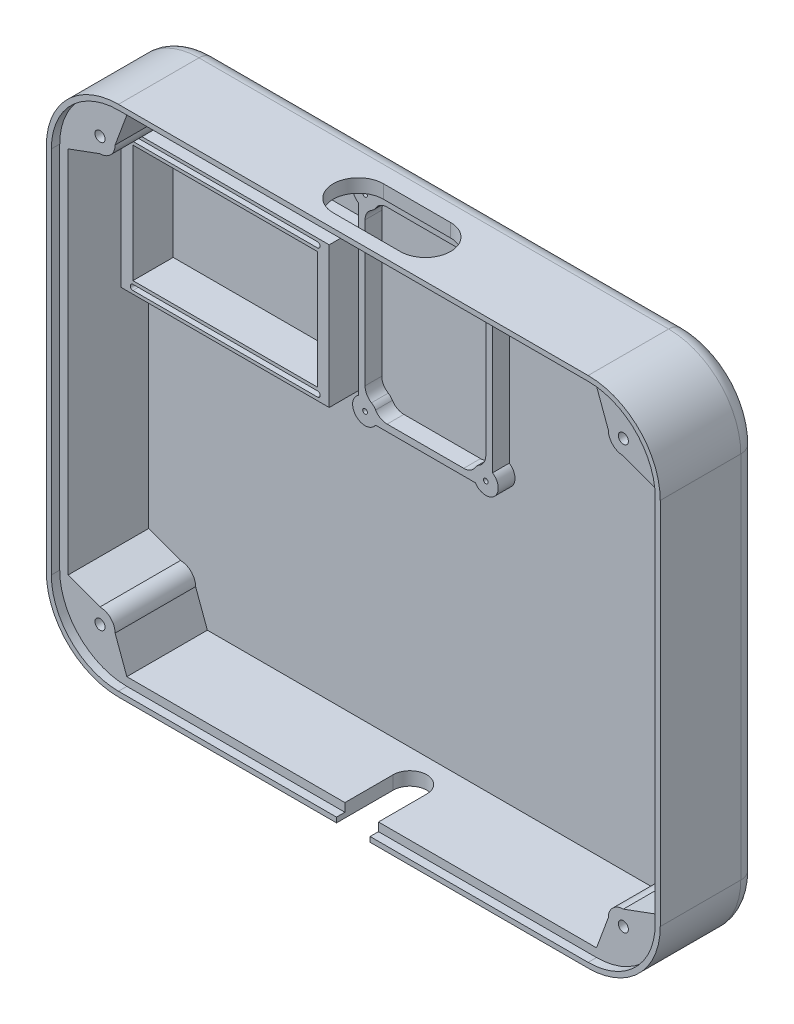
from build123d import *

# Parameters (mm, degrees)
BOSS_EXTRUDE1_DEPTH = 2.5
BOSS_EXTRUDE3_DEPTH = 26.5
BOSS_EXTRUDE5_DEPTH = 29
SKETCH2_R           = 1.5
BOSS_EXTRUDE6_DEPTH = 24
FILLET1_R           = 5
CUT_EXTRUDE1_DEPTH  = 10
SKETCH4_R           = 0.7
BOSS_EXTRUDE8_DEPTH = 5
CUT_EXTRUDE3_REACH  = 182.616
SKETCH6_W           = 55
SKETCH6_H           = 35
BOSS_EXTRUDE9_DEPTH = 12


with BuildPart() as part:
    # Sketch1 → Boss-Extrude1 (new body)
    with BuildSketch(Plane.XY):
        with BuildLine():
            Line((70, 72.5), (-70, 72.5))
            ThreePointArc((-70, 72.5), (-82.374368671, 67.374368671), (-87.5, 55))
            Line((-87.5, 55), (-87.5, -55))
            ThreePointArc((-87.5, -55), (-82.374368671, -67.374368671), (-70, -72.5))
            Line((-70, -72.5), (70, -72.5))
            ThreePointArc((70, -72.5), (82.374368671, -67.374368671), (87.5, -55))
            Line((87.5, -55), (87.5, 55))
            ThreePointArc((87.5, 55), (82.374368671, 67.374368671), (70, 72.5))
        make_face()
    extrude(amount=BOSS_EXTRUDE1_DEPTH)

    # Sketch1_4 → Boss-Extrude3 (add)
    with BuildSketch(Plane.XY):
        with BuildLine():
            Line((-70, 75), (70, 75))
            ThreePointArc((70, 75), (84.142135624, 69.142135624), (90, 55))
            Line((90, 55), (90, -55))
            ThreePointArc((90, -55), (84.142135624, -69.142135624), (70, -75))
            Line((70, -75), (-70, -75))
            ThreePointArc((-70, -75), (-84.142135624, -69.142135624), (-90, -55))
            Line((-90, -55), (-90, 55))
            ThreePointArc((-90, 55), (-84.142135624, 69.142135624), (-70, 75))
        make_face()
        with BuildLine():
            Line((-70, 72.5), (70, 72.5))
            ThreePointArc((70, 72.5), (82.374368671, 67.374368671), (87.5, 55))
            Line((87.5, 55), (87.5, -55))
            ThreePointArc((87.5, -55), (82.374368671, -67.374368671), (70, -72.5))
            Line((70, -72.5), (-70, -72.5))
            ThreePointArc((-70, -72.5), (-82.374368671, -67.374368671), (-87.5, -55))
            Line((-87.5, -55), (-87.5, 55))
            ThreePointArc((-87.5, 55), (-82.374368671, 67.374368671), (-70, 72.5))
        make_face(mode=Mode.SUBTRACT)
    extrude(amount=BOSS_EXTRUDE3_DEPTH)

    # Sketch1_6 → Boss-Extrude5 (add)
    with BuildSketch(Plane.XY):
        with BuildLine():
            Line((70, 76.5), (-70, 76.5))
            ThreePointArc((-70, 76.5), (-85.202795796, 70.202795796), (-91.5, 55))
            Line((-91.5, 55), (-91.5, -55))
            ThreePointArc((-91.5, -55), (-85.202795796, -70.202795796), (-70, -76.5))
            Line((-70, -76.5), (70, -76.5))
            ThreePointArc((70, -76.5), (85.202795796, -70.202795796), (91.5, -55))
            Line((91.5, -55), (91.5, 55))
            ThreePointArc((91.5, 55), (85.202795796, 70.202795796), (70, 76.5))
        make_face()
        with BuildLine():
            ThreePointArc((-90, 55), (-84.142135624, 69.142135624), (-70, 75))
            Line((-70, 75), (70, 75))
            ThreePointArc((70, 75), (84.142135624, 69.142135624), (90, 55))
            Line((90, 55), (90, -55))
            ThreePointArc((90, -55), (84.142135624, -69.142135624), (70, -75))
            Line((70, -75), (-70, -75))
            ThreePointArc((-70, -75), (-84.142135624, -69.142135624), (-90, -55))
            Line((-90, -55), (-90, 55))
        make_face(mode=Mode.SUBTRACT)
    extrude(amount=BOSS_EXTRUDE5_DEPTH)

    # Sketch2 → Boss-Extrude6 (add)
    # profile 1 of 4: a face of its own
    with BuildSketch(Plane.XY.offset(2.5)):
        with BuildLine():
            Line((87.5, -55), (78, -58.5))
            ThreePointArc((78, -58.5), (74.818019485, -59.818019485), (73.5, -63))
            Line((73.5, -63), (70, -72.5))
            ThreePointArc((70, -72.5), (82.374368671, -67.374368671), (87.5, -55))
        make_face()
        with Locations((78, -63)):
            Circle(SKETCH2_R, mode=Mode.SUBTRACT)
    # profile 2 of 4: a face of its own
    with BuildSketch(Plane.XY.offset(2.5)):
        with BuildLine():
            Line((70, 72.5), (73.5, 63))
            ThreePointArc((73.5, 63), (74.818019485, 59.818019485), (78, 58.5))
            Line((78, 58.5), (87.5, 55))
            ThreePointArc((87.5, 55), (82.374368671, 67.374368671), (70, 72.5))
        make_face()
        with Locations((78, 63)):
            Circle(SKETCH2_R, mode=Mode.SUBTRACT)
    # profile 3 of 4: a face of its own
    with BuildSketch(Plane.XY.offset(2.5)):
        with BuildLine():
            ThreePointArc((-73.5, -63), (-74.818019485, -59.818019485), (-78, -58.5))
            Line((-78, -58.5), (-87.5, -55))
            ThreePointArc((-87.5, -55), (-82.374368671, -67.374368671), (-70, -72.5))
            Line((-70, -72.5), (-73.5, -63))
        make_face()
        with Locations((-78, -63)):
            Circle(SKETCH2_R, mode=Mode.SUBTRACT)
    # profile 4 of 4: a face of its own
    with BuildSketch(Plane.XY.offset(2.5)):
        with BuildLine():
            Line((-87.5, 55), (-78, 58.5))
            ThreePointArc((-78, 58.5), (-74.818019485, 59.818019485), (-73.5, 63))
            Line((-73.5, 63), (-70, 72.5))
            ThreePointArc((-70, 72.5), (-82.374368671, 67.374368671), (-87.5, 55))
        make_face()
        with Locations((-78, 63)):
            Circle(SKETCH2_R, mode=Mode.SUBTRACT)
    extrude(amount=BOSS_EXTRUDE6_DEPTH)

    # Fillet1
    fillet1_edges = [part.edges().sort_by_distance(p)[0] for p in [
        (-85.202795796, -70.202795796, 0),
        (-91.5, 0, 0),
        (-85.202795796, 70.202795796, 0),
        (0, 76.5, 0),
        (85.202795796, 70.202795796, 0),
        (0, -76.5, 0),
        (85.202795796, -70.202795796, 0),
        (91.5, 0, 0),
    ]]
    fillet(fillet1_edges, radius=FILLET1_R)

    # Sketch3 → Cut-Extrude1 (cut)
    with BuildSketch(Plane.XZ.offset(76.5)):
        with BuildLine():
            Line((-5, 29), (-5, 12.11379287))
            ThreePointArc((-5, 12.11379287), (0, 7.11379287), (5, 12.11379287))
            Line((5, 12.11379287), (5, 29))
            Line((5, 29), (-5, 29))
        make_face()
    extrude(amount=-CUT_EXTRUDE1_DEPTH, mode=Mode.SUBTRACT)

    # Sketch4 → Boss-Extrude8 (add)
    with BuildSketch(Plane.XY.offset(2.5)):
        with BuildLine():
            Line((14.887123517, 10.5), (-14.887123517, 10.5))
            ThreePointArc((-14.887123517, 10.5), (-20.61629509, 9.88370491), (-20, 15.612876483))
            Line((-20, 15.612876483), (-20, 65.387123517))
            ThreePointArc((-20, 65.387123517), (-20.61629509, 71.11629509), (-14.887123517, 70.5))
            Line((-14.887123517, 70.5), (14.887123517, 70.5))
            ThreePointArc((14.887123517, 70.5), (20.61629509, 71.11629509), (20, 65.387123517))
            Line((20, 65.387123517), (20, 15.612876483))
            ThreePointArc((20, 15.612876483), (20.61629509, 9.88370491), (14.887123517, 10.5))
        make_face()
        with Locations((18, 12.5)):
            Circle(SKETCH4_R, mode=Mode.SUBTRACT)
        with Locations((-18, 12.5)):
            Circle(SKETCH4_R, mode=Mode.SUBTRACT)
        with Locations((-18, 68.5)):
            Circle(SKETCH4_R, mode=Mode.SUBTRACT)
        with Locations((18, 68.5)):
            Circle(SKETCH4_R, mode=Mode.SUBTRACT)
        with BuildLine():
            Line((11.42048634, 12.5), (-11.42048634, 12.5))
            ThreePointArc((-11.42048634, 12.5), (-13.381138233, 13.013476781), (-14.838415514, 14.422077922))
            ThreePointArc((-14.838415514, 14.422077922), (-15.38370491, 15.11629509), (-16.077922078, 15.661584486))
            ThreePointArc((-16.077922078, 15.661584486), (-17.486523219, 17.118861767), (-18, 19.07951366))
            Line((-18, 19.07951366), (-18, 61.92048634))
            ThreePointArc((-18, 61.92048634), (-17.486523219, 63.881138233), (-16.077922078, 65.338415514))
            ThreePointArc((-16.077922078, 65.338415514), (-15.38370491, 65.88370491), (-14.838415514, 66.577922078))
            ThreePointArc((-14.838415514, 66.577922078), (-13.381138233, 67.986523219), (-11.42048634, 68.5))
            Line((-11.42048634, 68.5), (11.42048634, 68.5))
            ThreePointArc((11.42048634, 68.5), (13.381138233, 67.986523219), (14.838415514, 66.577922078))
            ThreePointArc((14.838415514, 66.577922078), (15.38370491, 65.88370491), (16.077922078, 65.338415514))
            ThreePointArc((16.077922078, 65.338415514), (17.486523219, 63.881138233), (18, 61.92048634))
            Line((18, 61.92048634), (18, 19.07951366))
            ThreePointArc((18, 19.07951366), (17.486523219, 17.118861767), (16.077922078, 15.661584486))
            ThreePointArc((16.077922078, 15.661584486), (15.38370491, 15.11629509), (14.838415514, 14.422077922))
            ThreePointArc((14.838415514, 14.422077922), (13.381138233, 13.013476781), (11.42048634, 12.5))
        make_face(mode=Mode.SUBTRACT)
    extrude(amount=BOSS_EXTRUDE8_DEPTH)

    # Sketch5 → Cut-Extrude3 (cut, up to next)
    with BuildSketch(Plane(origin=(0, 76.5, 0), x_dir=(1, 0, 0), z_dir=(0, 1, 0)), mode=Mode.PRIVATE) as cut_extrude3_sk1:
        with BuildLine():
            Line((10, -25), (-10, -25))
            ThreePointArc((-10, -25), (-17.5, -17.5), (-10, -10))
            Line((-10, -10), (10, -10))
            ThreePointArc((10, -10), (17.5, -17.5), (10, -25))
        make_face()
    cut_extrude3_tool1 = extrude(cut_extrude3_sk1.sketch, amount=-CUT_EXTRUDE3_REACH, mode=Mode.PRIVATE) & part.part
    add(cut_extrude3_tool1.solids().sort_by_distance((0, 76.5, 17.5))[0], mode=Mode.SUBTRACT)

    # Sketch6 → Boss-Extrude9 (add)
    with BuildSketch(Plane.XY.offset(2.5)):
        Polygon((-83.678083714, 15.14631801), (-21.678083714, 15.14631801), (-21.678083714, 57.14631801), (-81.674279688, 57.14631801), (-83.678083714, 56.408074421), align=None)
        with BuildLine():
            Line((-80.178083714, 56.19631801), (-25.178083714, 56.19631801))
            ThreePointArc((-25.178083714, 56.19631801), (-24.378083714, 55.39631801), (-25.178083714, 54.59631801))
            Line((-25.178083714, 54.59631801), (-80.178083714, 54.59631801))
            ThreePointArc((-80.178083714, 54.59631801), (-80.978083714, 55.39631801), (-80.178083714, 56.19631801))
        make_face(mode=Mode.SUBTRACT)
        with Locations((-52.678083714, 36.14631801)):
            Rectangle(SKETCH6_W, SKETCH6_H, mode=Mode.SUBTRACT)
        with BuildLine():
            ThreePointArc((-80.178083714, 16.09631801), (-80.978083714, 16.89631801), (-80.178083714, 17.69631801))
            Line((-80.178083714, 17.69631801), (-25.178083714, 17.69631801))
            ThreePointArc((-25.178083714, 17.69631801), (-24.378083714, 16.89631801), (-25.178083714, 16.09631801))
            Line((-25.178083714, 16.09631801), (-80.178083714, 16.09631801))
        make_face(mode=Mode.SUBTRACT)
    extrude(amount=BOSS_EXTRUDE9_DEPTH)


solid = part.part
